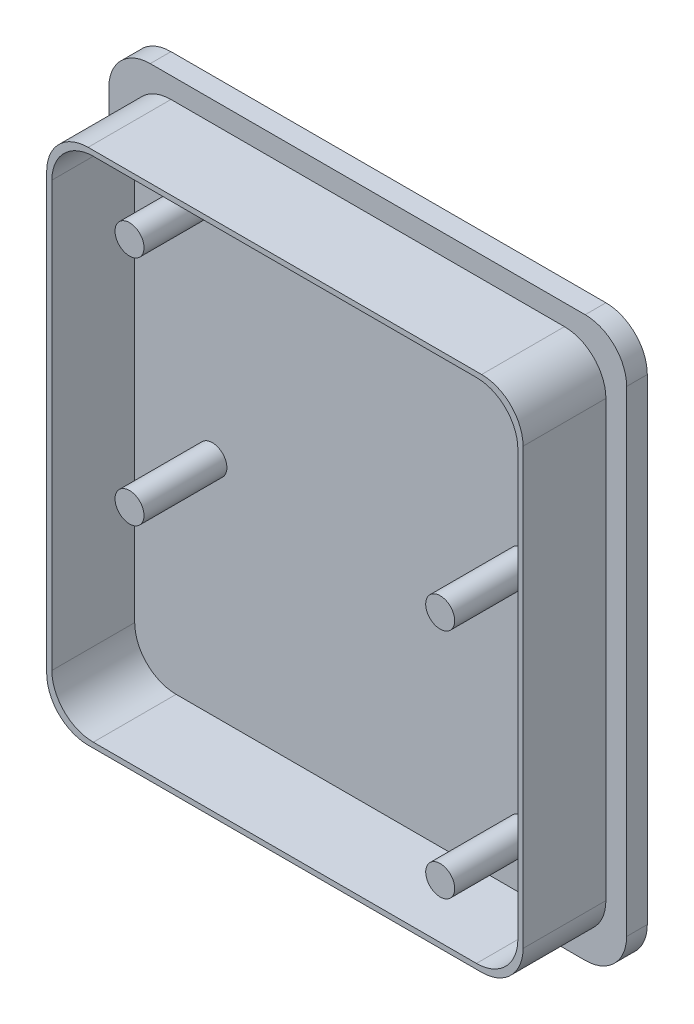
from build123d import *

# Parameters (mm, degrees)
BOSS_EXTRUDE1_DEPTH = 10
SKETCH3_R           = 1.4
CUT_EXTRUDE2_DEPTH  = 8


with BuildPart() as part:
    # Sketch1 → Boss-Extrude1 (new body)
    with BuildSketch(Plane.XY):
        with BuildLine():
            Line((-21, -27), (21, -27))
            ThreePointArc((21, -27), (23.828427125, -25.828427125), (25, -23))
            Line((25, -23), (25, 23))
            ThreePointArc((25, 23), (23.828427125, 25.828427125), (21, 27))
            Line((21, 27), (-21, 27))
            ThreePointArc((-21, 27), (-23.828427125, 25.828427125), (-25, 23))
            Line((-25, 23), (-25, -23))
            ThreePointArc((-25, -23), (-23.828427125, -25.828427125), (-21, -27))
        make_face()
    extrude(amount=BOSS_EXTRUDE1_DEPTH)

    # Sketch3 → Cut-Extrude2 (cut)
    with BuildSketch(Plane.XY.offset(10)):
        with BuildLine():
            Line((21, 27), (-21, 27))
            ThreePointArc((-21, 27), (-23.828427125, 25.828427125), (-25, 23))
            Line((-25, 23), (-25, -23))
            ThreePointArc((-25, -23), (-23.828427125, -25.828427125), (-21, -27))
            Line((-21, -27), (21, -27))
            ThreePointArc((21, -27), (23.828427125, -25.828427125), (25, -23))
            Line((25, -23), (25, 23))
            ThreePointArc((25, 23), (23.828427125, 25.828427125), (21, 27))
        make_face()
        with BuildLine():
            Line((-19, -25), (19, -25))
            ThreePointArc((19, -25), (21.828427125, -23.828427125), (23, -21))
            Line((23, -21), (23, 21))
            ThreePointArc((23, 21), (21.828427125, 23.828427125), (19, 25))
            Line((19, 25), (-19, 25))
            ThreePointArc((-19, 25), (-21.828427125, 23.828427125), (-23, 21))
            Line((-23, 21), (-23, -21))
            ThreePointArc((-23, -21), (-21.828427125, -23.828427125), (-19, -25))
        make_face(mode=Mode.SUBTRACT)
        with BuildLine():
            Line((-18.5, -24.5), (18.5, -24.5))
            ThreePointArc((18.5, -24.5), (21.328427125, -23.328427125), (22.5, -20.5))
            Line((22.5, -20.5), (22.5, 20.5))
            ThreePointArc((22.5, 20.5), (21.328427125, 23.328427125), (18.5, 24.5))
            Line((18.5, 24.5), (-18.5, 24.5))
            ThreePointArc((-18.5, 24.5), (-21.328427125, 23.328427125), (-22.5, 20.5))
            Line((-22.5, 20.5), (-22.5, -20.5))
            ThreePointArc((-22.5, -20.5), (-21.328427125, -23.328427125), (-18.5, -24.5))
        make_face()
        with Locations((-15, -3.1)):
            Circle(SKETCH3_R, mode=Mode.SUBTRACT)
        with Locations((15, 3.1)):
            Circle(SKETCH3_R, mode=Mode.SUBTRACT)
        with Locations((-15, 19.3)):
            Circle(SKETCH3_R, mode=Mode.SUBTRACT)
        with Locations((15, -19.3)):
            Circle(SKETCH3_R, mode=Mode.SUBTRACT)
    extrude(amount=-CUT_EXTRUDE2_DEPTH, mode=Mode.SUBTRACT)


solid = part.part
